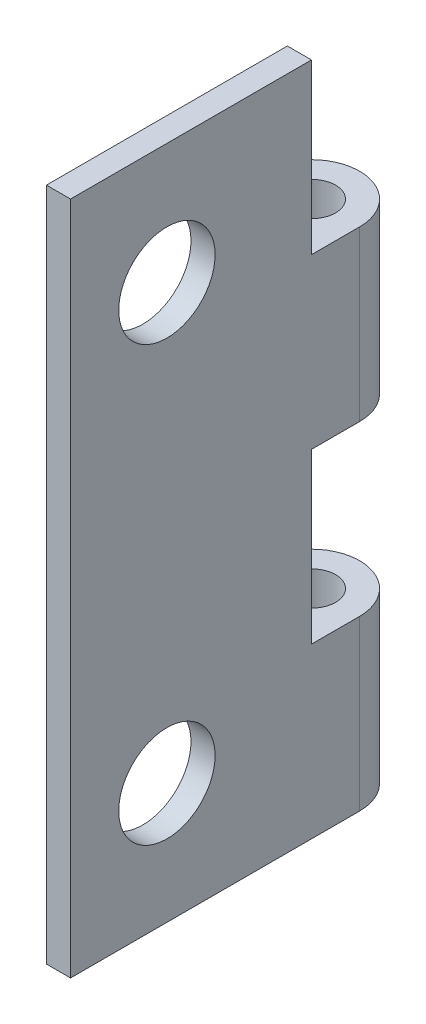
from build123d import *

# Parameters (mm, degrees)
SKETCH1_R           = 1
BOSS_EXTRUDE1_DEPTH = 28
SKETCH2_W           = 5.706880649
SKETCH2_H           = 7
CUT_EXTRUDE1_DEPTH  = 5
SKETCH3_R           = 2
CUT_EXTRUDE2_DEPTH  = 5


with BuildPart() as part:
    # Sketch1 → Boss-Extrude1 (new body)
    with BuildSketch(Plane(origin=(0, 0, 0), x_dir=(1, 0, 0), z_dir=(0, 1, 0))):
        with BuildLine():
            ThreePointArc((0.266683504, 3), (-3.465367303, 4), (-0.733316496, 1.267949192))
            Line((-0.733316496, 1.267949192), (-0.733316496, -9))
            Line((-0.733316496, -9), (0.266683504, -9))
            Line((0.266683504, -9), (0.266683504, 3))
        make_face()
        with Locations((-1.733316496, 3)):
            Circle(SKETCH1_R, mode=Mode.SUBTRACT)
    extrude(amount=BOSS_EXTRUDE1_DEPTH)

    # Sketch2 → Cut-Extrude1 (cut, through all)
    with BuildSketch(Plane(origin=(0.266683504, 0, 0), x_dir=(0, 0, -1), z_dir=(1, 0, 0))):
        with Locations((3.853440325, 24.5)):
            Rectangle(SKETCH2_W, SKETCH2_H)
        with Locations((3.853440325, 10.5)):
            Rectangle(SKETCH2_W, SKETCH2_H)
    extrude(amount=-CUT_EXTRUDE1_DEPTH, mode=Mode.SUBTRACT)

    # Sketch3 → Cut-Extrude2 (cut, through all)
    with BuildSketch(Plane(origin=(0.266683504, 0, 0), x_dir=(0, 0, -1), z_dir=(1, 0, 0))):
        with Locations((-5, 23)):
            Circle(SKETCH3_R)
        with Locations((-5, 5)):
            Circle(SKETCH3_R)
    extrude(amount=-CUT_EXTRUDE2_DEPTH, mode=Mode.SUBTRACT)


solid = part.part
